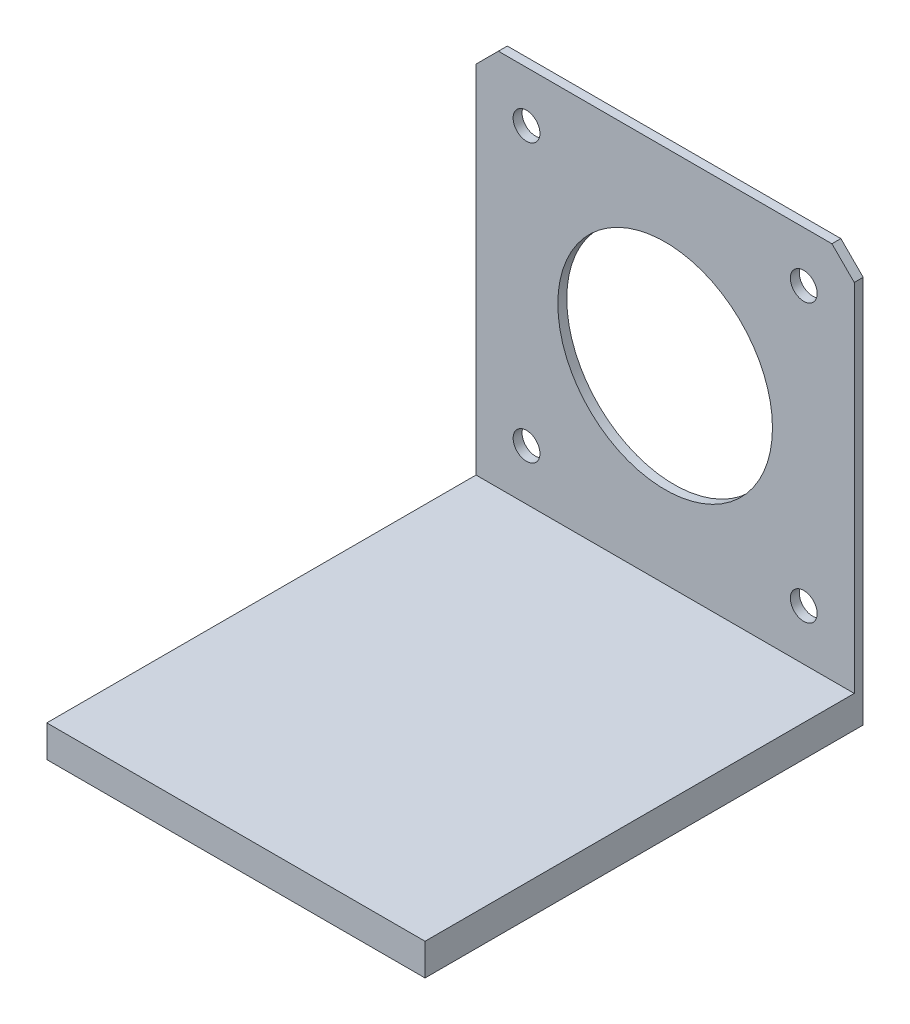
from build123d import *

# Parameters (mm, degrees)
SKETCH1_W            = 42.3
SKETCH1_H            = 42.3
BOSS_EXTRUDE1_DEPTH  = 1
SKETCH3_R            = 0.5
CUT_EXTRUDE1_DEPTH   = 2
CHAMFER1_SIZE        = 2.5
SKETCH4_R            = 12
CUT_EXTRUDE2_DEPTH   = 2
SKETCH5_R            = 1.5
CUT_EXTRUDE3_DEPTH   = 2
SKETCH6_W            = 42.3
SKETCH6_H            = 1
BOSS_EXTRUDE2_DEPTH  = 3.21
SKETCH7_W            = 42.3
SKETCH7_H            = 5.71
BOSS_EXTRUDE3_DEPTH  = 1
SKETCH8_W            = 42.3
SKETCH8_H            = 1
BOSS_EXTRUDE4_DEPTH  = 0.35
SKETCH9_W            = 42.3
SKETCH9_H            = 1
BOSS_EXTRUDE5_DEPTH  = 48
SKETCH10_W           = 42.3
SKETCH10_H           = 1
BOSS_EXTRUDE6_DEPTH  = 2.56
SKETCH11_W           = 49
SKETCH11_H           = 3.56
BOSS_EXTRUDE7_DEPTH  = 1
SKETCH12_W           = 5
SKETCH12_H           = 1
BOSS_EXTRUDE8_DEPTH  = 5
SKETCH13_W           = 49
SKETCH13_H           = 3.56
BOSS_EXTRUDE9_DEPTH  = 1
SKETCH14_W           = 5
SKETCH14_H           = 5
BOSS_EXTRUDE10_DEPTH = 3.56
SKETCH15_W           = 5
SKETCH15_H           = 2.56
CUT_EXTRUDE4_DEPTH   = 5
SKETCH16_R           = 1
CUT_EXTRUDE5_DEPTH   = 5
SKETCH17_W           = 5
SKETCH17_H           = 5
SKETCH17_R           = 1
BOSS_EXTRUDE11_DEPTH = 2.56
CUT_EXTRUDE6_DEPTH   = 5
SKETCH20_W           = 5
SKETCH20_H           = 3.56
BOSS_EXTRUDE12_DEPTH = 1
SKETCH21_W           = 6
SKETCH21_H           = 3.56
BOSS_EXTRUDE13_DEPTH = 1
SKETCH22_W           = 6
SKETCH22_H           = 3.56
BOSS_EXTRUDE14_DEPTH = 1
SKETCH23_W           = 5
SKETCH23_H           = 5
BOSS_EXTRUDE15_DEPTH = 2.56
SKETCH24_W           = 5
SKETCH24_H           = 3.56
BOSS_EXTRUDE16_DEPTH = 1
SKETCH25_W           = 5
SKETCH25_H           = 3.56
BOSS_EXTRUDE17_DEPTH = 1
SKETCH26_W           = 7
SKETCH26_H           = 3.56
BOSS_EXTRUDE18_DEPTH = 1
CUT_EXTRUDE7_DEPTH   = 21
SKETCH31_W           = 6
SKETCH31_H           = 7
CUT_EXTRUDE8_DEPTH   = 4.56
SKETCH32_W           = 6
SKETCH32_H           = 7
BOSS_EXTRUDE19_DEPTH = 2.56
BOSS_EXTRUDE20_START = -2.56
SKETCH34_W           = 6
SKETCH34_H           = 7
BOSS_EXTRUDE20_DEPTH = 2.56
SKETCH35_W           = 6
SKETCH35_H           = 7
CUT_EXTRUDE9_DEPTH   = 46.86


with BuildPart() as part:
    # Sketch1 → Boss-Extrude1 (new body)
    with BuildSketch(Plane.XY):
        with Locations((-4.664501511, -3.32265861)):
            Rectangle(SKETCH1_W, SKETCH1_H)
    extrude(amount=BOSS_EXTRUDE1_DEPTH)

    # Sketch3 → Cut-Extrude1 (cut, through all)
    with BuildSketch(Plane.XY.offset(1)):
        with Locations((-20.164501511, -18.82265861)):
            Circle(SKETCH3_R)
        with Locations((10.835498489, -18.82265861)):
            Circle(SKETCH3_R)
        with Locations((10.835498489, 12.17734139)):
            Circle(SKETCH3_R)
        with Locations((-20.164501511, 12.17734139)):
            Circle(SKETCH3_R)
    extrude(amount=-CUT_EXTRUDE1_DEPTH, mode=Mode.SUBTRACT)

    # Chamfer1
    chamfer1_edges = [part.edges().sort_by_distance(p)[0] for p in [
        (-25.814501511, 17.82734139, 0.5),
        (16.485498489, 17.82734139, 0.5),
        (16.485498489, -24.47265861, 0.5),
        (-25.814501511, -24.47265861, 0.5),
    ]]
    chamfer(chamfer1_edges, length=CHAMFER1_SIZE)

    # Sketch4 → Cut-Extrude2 (cut, through all)
    with BuildSketch(Plane.XY.offset(1)):
        with Locations((-4.664501511, -3.32265861)):
            Circle(SKETCH4_R)
    extrude(amount=-CUT_EXTRUDE2_DEPTH, mode=Mode.SUBTRACT)

    # Sketch5 → Cut-Extrude3 (cut, through all)
    with BuildSketch(Plane.XY.offset(1)):
        with Locations((-20.164501511, 12.17734139)):
            Circle(SKETCH5_R)
        with Locations((-20.164501511, -18.82265861)):
            Circle(SKETCH5_R)
        with Locations((10.835498489, -18.82265861)):
            Circle(SKETCH5_R)
        with Locations((10.835498489, 12.17734139)):
            Circle(SKETCH5_R)
    extrude(amount=-CUT_EXTRUDE3_DEPTH, mode=Mode.SUBTRACT)

    # Sketch6 → Boss-Extrude2 (add)
    with BuildSketch(Plane.XZ.offset(24.47265861)):
        with Locations((-4.664501511, 0.5)):
            Rectangle(SKETCH6_W, SKETCH6_H)
    extrude(amount=BOSS_EXTRUDE2_DEPTH)

    # Sketch7 → Boss-Extrude3 (add)
    with BuildSketch(Plane.XY.offset(1)):
        with Locations((-4.664501511, -24.82765861)):
            Rectangle(SKETCH7_W, SKETCH7_H)
    extrude(amount=-BOSS_EXTRUDE3_DEPTH)

    # Sketch8 → Boss-Extrude4 (add)
    with BuildSketch(Plane.XZ.offset(27.68265861)):
        with Locations((-4.664501511, 0.5)):
            Rectangle(SKETCH8_W, SKETCH8_H)
    extrude(amount=BOSS_EXTRUDE4_DEPTH)

    # Sketch9 → Boss-Extrude5 (add)
    with BuildSketch(Plane.XY.offset(1)):
        with Locations((-4.664501511, -24.97265861)):
            Rectangle(SKETCH9_W, SKETCH9_H)
    extrude(amount=BOSS_EXTRUDE5_DEPTH)

    # Sketch10 → Boss-Extrude6 (add)
    with BuildSketch(Plane.XZ.offset(25.47265861)):
        with Locations((-4.664501511, 48.5)):
            Rectangle(SKETCH10_W, SKETCH10_H)
    extrude(amount=BOSS_EXTRUDE6_DEPTH)

    # Sketch11 → Boss-Extrude7 (add)
    with BuildSketch(Plane.ZY.offset(25.814501511)):
        with Locations((24.5, -26.25265861)):
            Rectangle(SKETCH11_W, SKETCH11_H)
    extrude(amount=-BOSS_EXTRUDE7_DEPTH)

    # Sketch12 → Boss-Extrude8 (add)
    with BuildSketch(Plane.ZY.offset(25.814501511)):
        with Locations((24.5, -27.53265861)):
            Rectangle(SKETCH12_W, SKETCH12_H)
    extrude(amount=BOSS_EXTRUDE8_DEPTH)

    # Sketch13 → Boss-Extrude9 (add)
    with BuildSketch(Plane(origin=(16.485498489, 0, 0), x_dir=(0, 0, -1), z_dir=(1, 0, 0))):
        with Locations((-24.5, -26.25265861)):
            Rectangle(SKETCH13_W, SKETCH13_H)
    extrude(amount=-BOSS_EXTRUDE9_DEPTH)

    # Sketch14 → Boss-Extrude10 (add)
    with BuildSketch(Plane(origin=(0, -24.47265861, 0), x_dir=(1, 0, 0), z_dir=(0, 1, 0))):
        with Locations((18.985498489, -24.5)):
            Rectangle(SKETCH14_W, SKETCH14_H)
    extrude(amount=-BOSS_EXTRUDE10_DEPTH)

    # Sketch15 → Cut-Extrude4 (cut)
    with BuildSketch(Plane(origin=(21.485498489, 0, 0), x_dir=(0, 0, -1), z_dir=(1, 0, 0))):
        with Locations((-24.5, -25.75265861)):
            Rectangle(SKETCH15_W, SKETCH15_H)
    extrude(amount=-CUT_EXTRUDE4_DEPTH, mode=Mode.SUBTRACT)

    # Sketch16 → Cut-Extrude5 (cut)
    with BuildSketch(Plane(origin=(0, -27.03265861, 0), x_dir=(1, 0, 0), z_dir=(0, 1, 0))):
        with Locations((-28.314501511, -24.5)):
            Circle(SKETCH16_R)
        with Locations((18.985498489, -24.5)):
            Circle(SKETCH16_R)
    extrude(amount=-CUT_EXTRUDE5_DEPTH, mode=Mode.SUBTRACT)

    # Sketch17 → Boss-Extrude11 (add)
    with BuildSketch(Plane(origin=(0, -27.03265861, 0), x_dir=(1, 0, 0), z_dir=(0, 1, 0))):
        with Locations((-28.314501511, -24.5)):
            Rectangle(SKETCH17_W, SKETCH17_H)
        with Locations((-28.314501511, -24.5)):
            Circle(SKETCH17_R, mode=Mode.SUBTRACT)
    extrude(amount=BOSS_EXTRUDE11_DEPTH)

    # Sketch19 → Cut-Extrude6 (cut)
    with BuildSketch(Plane(origin=(0, -24.47265861, 0), x_dir=(1, 0, 0), z_dir=(0, 1, 0))):
        Polygon((-29.469202049, -26.5), (-27.159800972, -26.5), (-26.005100434, -24.5), (-27.159800972, -22.5), (-29.469202049, -22.5), (-30.623902587, -24.5), align=None)
    extrude(amount=-CUT_EXTRUDE6_DEPTH, mode=Mode.SUBTRACT)

    # Sketch20 → Boss-Extrude12 (add)
    with BuildSketch(Plane.ZY.offset(30.814501511)):
        with Locations((24.5, -26.25265861)):
            Rectangle(SKETCH20_W, SKETCH20_H)
    extrude(amount=BOSS_EXTRUDE12_DEPTH)

    # Sketch21 → Boss-Extrude13 (add)
    with BuildSketch(Plane.XY.offset(27)):
        with Locations((-28.814501511, -26.25265861)):
            Rectangle(SKETCH21_W, SKETCH21_H)
    extrude(amount=BOSS_EXTRUDE13_DEPTH)

    # Sketch22 → Boss-Extrude14 (add)
    with BuildSketch(Plane(origin=(0, 0, 22), x_dir=(-1, 0, 0), z_dir=(0, 0, -1))):
        with Locations((28.814501511, -26.25265861)):
            Rectangle(SKETCH22_W, SKETCH22_H)
    extrude(amount=BOSS_EXTRUDE14_DEPTH)

    # Sketch23 → Boss-Extrude15 (add)
    with BuildSketch(Plane(origin=(0, -27.03265861, 0), x_dir=(1, 0, 0), z_dir=(0, 1, 0))):
        with Locations((18.985498489, -24.5)):
            Rectangle(SKETCH23_W, SKETCH23_H)
    extrude(amount=BOSS_EXTRUDE15_DEPTH)

    # Sketch24 → Boss-Extrude16 (add)
    with BuildSketch(Plane.XY.offset(27)):
        with Locations((18.985498489, -26.25265861)):
            Rectangle(SKETCH24_W, SKETCH24_H)
    extrude(amount=BOSS_EXTRUDE16_DEPTH)

    # Sketch25 → Boss-Extrude17 (add)
    with BuildSketch(Plane(origin=(0, 0, 22), x_dir=(-1, 0, 0), z_dir=(0, 0, -1))):
        with Locations((-18.985498489, -26.25265861)):
            Rectangle(SKETCH25_W, SKETCH25_H)
    extrude(amount=BOSS_EXTRUDE17_DEPTH)

    # Sketch26 → Boss-Extrude18 (add)
    with BuildSketch(Plane(origin=(21.485498489, 0, 0), x_dir=(0, 0, -1), z_dir=(1, 0, 0))):
        with Locations((-24.5, -26.25265861)):
            Rectangle(SKETCH26_W, SKETCH26_H)
    extrude(amount=BOSS_EXTRUDE18_DEPTH)

    # Sketch29 → Cut-Extrude7 (cut)
    with BuildSketch(Plane(origin=(0, -24.47265861, 0), x_dir=(1, 0, 0), z_dir=(0, 1, 0))):
        Polygon((20.640199028, -26.5), (21.794899566, -24.5), (20.640199028, -22.5), (18.330797951, -22.5), (17.176097413, -24.5), (18.330797951, -26.5), align=None)
    extrude(amount=-CUT_EXTRUDE7_DEPTH, mode=Mode.SUBTRACT)

    # Sketch31 → Cut-Extrude8 (cut, through all)
    with BuildSketch(Plane(origin=(0, -24.47265861, 0), x_dir=(1, 0, 0), z_dir=(0, 1, 0))):
        with Locations((19.485498489, -24.5)):
            Rectangle(SKETCH31_W, SKETCH31_H)
    extrude(amount=-CUT_EXTRUDE8_DEPTH, mode=Mode.SUBTRACT)

    # Sketch32 → Boss-Extrude19 (add)
    with BuildSketch(Plane.XZ.offset(25.47265861)):
        with Locations((-21.814501511, 24.5)):
            Rectangle(SKETCH32_W, SKETCH32_H)
    extrude(amount=BOSS_EXTRUDE19_DEPTH)

    # Sketch34 → Boss-Extrude20 (add)
    with BuildSketch(Plane(origin=(0, -28.03265861, 0), x_dir=(-1, 0, 0), z_dir=(0, -1, 0)).offset(BOSS_EXTRUDE20_START)):
        with Locations((-12.485498489, -24.5)):
            Rectangle(SKETCH34_W, SKETCH34_H)
    extrude(amount=BOSS_EXTRUDE20_DEPTH)

    # Sketch35 → Cut-Extrude9 (cut, through all)
    with BuildSketch(Plane.XZ.offset(28.03265861)):
        with Locations((-28.814501511, 24.5)):
            Rectangle(SKETCH35_W, SKETCH35_H)
    extrude(amount=-CUT_EXTRUDE9_DEPTH, mode=Mode.SUBTRACT)


solid = part.part
